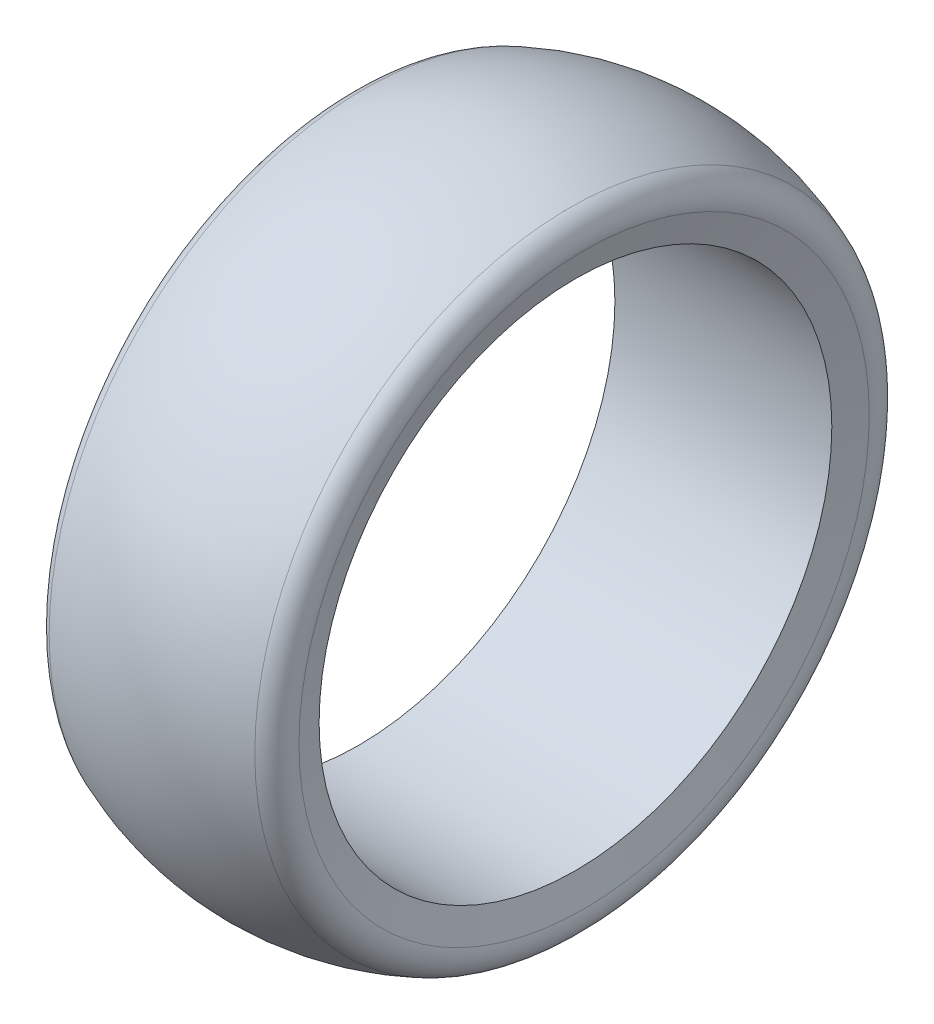
from build123d import *

# Parameters (mm, degrees)
FILETE1_R = 2.5


with BuildPart() as part:
    # Esboço2 → Revolução1 (revolve)
    with BuildSketch(Plane.XY):
        with BuildLine():
            Line((25, 31), (23.5, 26))
            Line((23.5, 26), (1.5, 26))
            Line((1.5, 26), (0, 31))
            ThreePointArc((0, 31), (12.5, 34), (25, 31))
        make_face()
    revolve(axis=Axis((0, 0, 0), (1, 0, 0)))

    # Filete1
    filete1_edges = [part.edges().sort_by_distance(p)[0] for p in [
        (0, -31, 0),
        (25, -31, 0),
    ]]
    fillet(filete1_edges, radius=FILETE1_R)


solid = part.part
